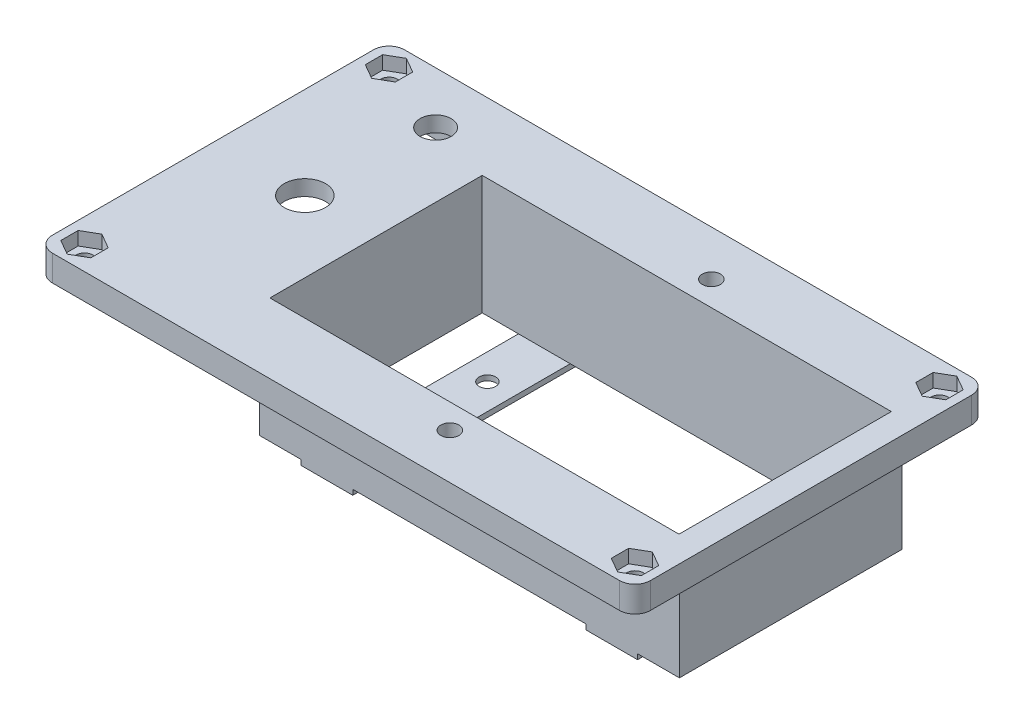
from build123d import *

# Parameters (mm, degrees)
SKETCH_1_R            = 1.6
EXTRUDE_1_DEPTH       = 2
EXTRUDE_1_2_DEPTH     = 4
CUT_EXTRUDE_5_DEPTH   = 2.01
SKETCH_4_R            = 1.6
EXTRUDE_2_DEPTH       = 3
CUT_EXTRUDE_1_DEPTH   = 2.6
SKETCH_6_W            = 79
SKETCH_6_H            = 41
CUT_EXTRUDE_2_DEPTH   = 8
SKETCH_7_W            = 81.076448847
SKETCH_7_H            = 43
SKETCH_7_W_2          = 79
SKETCH_7_H_2          = 41
EXTRUDE_3_DEPTH       = 20
SKETCH_9_R            = 3
CUT_EXTRUDE_3_DEPTH   = 4
SKETCH_10_R           = 4
CUT_EXTRUDE_4_DEPTH   = 4
SKETCH_11_W           = 10
SKETCH_11_H           = 43
SKETCH_11_R           = 1.6
EXTRUDE_4_DEPTH       = 1
SKETCH_12_W           = 10
SKETCH_12_H           = 7.5
EXTRUDE_5_DEPTH       = 3
SKETCH_13_R           = 1.75
CUT_EXTRUDE_5_2_DEPTH = 4


with BuildPart() as part:
    # Эскиз1 → Extrude 1 (new body)
    with BuildSketch(Plane(origin=(0, 0, 0), x_dir=(1, 0, 0), z_dir=(0, 1, 0))):
        with BuildLine():
            Line((55.077834671, -32.996915035), (-54.422165329, -32.996915035))
            ThreePointArc((-54.422165329, -32.996915035), (-56.543485673, -32.118235378), (-57.422165329, -29.996915035))
            Line((-57.422165329, -29.996915035), (-57.422165329, 32.003084965))
            ThreePointArc((-57.422165329, 32.003084965), (-56.543485673, 34.124405309), (-54.422165329, 35.003084965))
            Line((-54.422165329, 35.003084965), (55.077834671, 35.003084965))
            ThreePointArc((55.077834671, 35.003084965), (57.199155014, 34.124405309), (58.077834671, 32.003084965))
            Line((58.077834671, 32.003084965), (58.077834671, -29.996915035))
            ThreePointArc((58.077834671, -29.996915035), (57.199155014, -32.118235378), (55.077834671, -32.996915035))
        make_face()
        with Locations((53.477834671, -28.396915035)):
            Circle(SKETCH_1_R, mode=Mode.SUBTRACT)
        with Locations((-52.822165329, -28.396915035)):
            Circle(SKETCH_1_R, mode=Mode.SUBTRACT)
        with Locations((-52.822165329, 30.403084965)):
            Circle(SKETCH_1_R, mode=Mode.SUBTRACT)
        with Locations((53.477834671, 30.403084965)):
            Circle(SKETCH_1_R, mode=Mode.SUBTRACT)
        with BuildLine():
            Line((55.077834671, 28.003084965), (55.077834671, -25.996915035))
            Line((55.077834671, -25.996915035), (52.577834671, -25.996915035))
            ThreePointArc((52.577834671, -25.996915035), (51.517174499, -26.436254863), (51.077834671, -27.496915035))
            Line((51.077834671, -27.496915035), (51.077834671, -29.996915035))
            Line((51.077834671, -29.996915035), (-50.422165329, -29.996915035))
            Line((-50.422165329, -29.996915035), (-50.422165329, -27.496915035))
            ThreePointArc((-50.422165329, -27.496915035), (-50.861505157, -26.436254863), (-51.922165329, -25.996915035))
            Line((-51.922165329, -25.996915035), (-54.422165329, -25.996915035))
            Line((-54.422165329, -25.996915035), (-54.422165329, 28.003084965))
            Line((-54.422165329, 28.003084965), (-51.922165329, 28.003084965))
            ThreePointArc((-51.922165329, 28.003084965), (-50.861505157, 28.442424793), (-50.422165329, 29.503084965))
            Line((-50.422165329, 29.503084965), (-50.422165329, 32.003084965))
            Line((-50.422165329, 32.003084965), (51.077834671, 32.003084965))
            Line((51.077834671, 32.003084965), (51.077834671, 29.503084965))
            ThreePointArc((51.077834671, 29.503084965), (51.517174499, 28.442424793), (52.577834671, 28.003084965))
            Line((52.577834671, 28.003084965), (55.077834671, 28.003084965))
        make_face(mode=Mode.SUBTRACT)
    extrude(amount=EXTRUDE_1_DEPTH)

    # Эскиз2 → Extrude 1 2 (add)
    with BuildSketch(Plane(origin=(0, 2, 0), x_dir=(1, 0, 0), z_dir=(0, 1, 0))):
        with BuildLine():
            Line((-51.922165329, 28.003084965), (-54.422165329, 28.003084965))
            Line((-54.422165329, 28.003084965), (-54.422165329, -25.996915035))
            Line((-54.422165329, -25.996915035), (-51.922165329, -25.996915035))
            ThreePointArc((-51.922165329, -25.996915035), (-50.861505157, -26.436254863), (-50.422165329, -27.496915035))
            Line((-50.422165329, -27.496915035), (-50.422165329, -29.996915035))
            Line((-50.422165329, -29.996915035), (51.077834671, -29.996915035))
            Line((51.077834671, -29.996915035), (51.077834671, -27.496915035))
            ThreePointArc((51.077834671, -27.496915035), (51.517174499, -26.436254863), (52.577834671, -25.996915035))
            Line((52.577834671, -25.996915035), (55.077834671, -25.996915035))
            Line((55.077834671, -25.996915035), (55.077834671, 28.003084965))
            Line((55.077834671, 28.003084965), (52.577834671, 28.003084965))
            ThreePointArc((52.577834671, 28.003084965), (51.517174499, 28.442424793), (51.077834671, 29.503084965))
            Line((51.077834671, 29.503084965), (51.077834671, 32.003084965))
            Line((51.077834671, 32.003084965), (-50.422165329, 32.003084965))
            Line((-50.422165329, 32.003084965), (-50.422165329, 29.503084965))
            ThreePointArc((-50.422165329, 29.503084965), (-50.861505157, 28.442424793), (-51.922165329, 28.003084965))
        make_face()
        with BuildLine():
            Line((-51.922165329, 26.003084965), (-52.422165329, 26.003084965))
            Line((-52.422165329, 26.003084965), (-52.422165329, -23.996915035))
            Line((-52.422165329, -23.996915035), (-51.922165329, -23.996915035))
            ThreePointArc((-51.922165329, -23.996915035), (-49.447291595, -25.022041301), (-48.422165329, -27.496915035))
            Line((-48.422165329, -27.496915035), (-48.422165329, -27.996915035))
            Line((-48.422165329, -27.996915035), (49.077834671, -27.996915035))
            Line((49.077834671, -27.996915035), (49.077834671, -27.496915035))
            ThreePointArc((49.077834671, -27.496915035), (50.102960937, -25.022041301), (52.577834671, -23.996915035))
            Line((52.577834671, -23.996915035), (53.077834671, -23.996915035))
            Line((53.077834671, -23.996915035), (53.077834671, 26.003084965))
            Line((53.077834671, 26.003084965), (52.577834671, 26.003084965))
            ThreePointArc((52.577834671, 26.003084965), (50.102960937, 27.028211231), (49.077834671, 29.503084965))
            Line((49.077834671, 29.503084965), (49.077834671, 30.003084965))
            Line((49.077834671, 30.003084965), (-48.422165329, 30.003084965))
            Line((-48.422165329, 30.003084965), (-48.422165329, 29.503084965))
            ThreePointArc((-48.422165329, 29.503084965), (-49.447291595, 27.028211231), (-51.922165329, 26.003084965))
        make_face(mode=Mode.SUBTRACT)
    extrude(amount=-EXTRUDE_1_2_DEPTH)

    # Эскиз3 → Cut-Extrude 5 (cut)
    with BuildSketch(Plane.XZ.offset(2)):
        with BuildLine():
            Line((-50.622165329, 27.496915035), (-50.622165329, 30.196915035))
            Line((-50.622165329, 30.196915035), (51.277834671, 30.196915035))
            Line((51.277834671, 30.196915035), (51.277834671, 27.496915035))
            ThreePointArc((51.277834671, 27.496915035), (51.658595855, 26.577676219), (52.577834671, 26.196915035))
            Line((52.577834671, 26.196915035), (55.277834671, 26.196915035))
            Line((55.277834671, 26.196915035), (55.277834671, -28.203084965))
            Line((55.277834671, -28.203084965), (52.577834671, -28.203084965))
            ThreePointArc((52.577834671, -28.203084965), (51.658595855, -28.58384615), (51.277834671, -29.503084965))
            Line((51.277834671, -29.503084965), (51.277834671, -32.203084965))
            Line((51.277834671, -32.203084965), (-50.622165329, -32.203084965))
            Line((-50.622165329, -32.203084965), (-50.622165329, -29.503084965))
            ThreePointArc((-50.622165329, -29.503084965), (-51.002926514, -28.58384615), (-51.922165329, -28.203084965))
            Line((-51.922165329, -28.203084965), (-54.622165329, -28.203084965))
            Line((-54.622165329, -28.203084965), (-54.622165329, 26.196915035))
            Line((-54.622165329, 26.196915035), (-51.922165329, 26.196915035))
            ThreePointArc((-51.922165329, 26.196915035), (-51.002926514, 26.577676219), (-50.622165329, 27.496915035))
        make_face()
        with BuildLine():
            Line((-50.422165329, 27.496915035), (-50.422165329, 29.996915035))
            Line((-50.422165329, 29.996915035), (51.077834671, 29.996915035))
            Line((51.077834671, 29.996915035), (51.077834671, 27.496915035))
            ThreePointArc((51.077834671, 27.496915035), (51.517174499, 26.436254863), (52.577834671, 25.996915035))
            Line((52.577834671, 25.996915035), (55.077834671, 25.996915035))
            Line((55.077834671, 25.996915035), (55.077834671, -28.003084965))
            Line((55.077834671, -28.003084965), (52.577834671, -28.003084965))
            ThreePointArc((52.577834671, -28.003084965), (51.517174499, -28.442424793), (51.077834671, -29.503084965))
            Line((51.077834671, -29.503084965), (51.077834671, -32.003084965))
            Line((51.077834671, -32.003084965), (-50.422165329, -32.003084965))
            Line((-50.422165329, -32.003084965), (-50.422165329, -29.503084965))
            ThreePointArc((-50.422165329, -29.503084965), (-50.861505157, -28.442424793), (-51.922165329, -28.003084965))
            Line((-51.922165329, -28.003084965), (-54.422165329, -28.003084965))
            Line((-54.422165329, -28.003084965), (-54.422165329, 25.996915035))
            Line((-54.422165329, 25.996915035), (-51.922165329, 25.996915035))
            ThreePointArc((-51.922165329, 25.996915035), (-50.861505157, 26.436254863), (-50.422165329, 27.496915035))
        make_face(mode=Mode.SUBTRACT)
    extrude(amount=-CUT_EXTRUDE_5_DEPTH, mode=Mode.SUBTRACT)

    # Эскиз4 → Бобышка-Вытянуть2 (add)
    with BuildSketch(Plane(origin=(0, 2, 0), x_dir=(1, 0, 0), z_dir=(0, 1, 0))):
        with BuildLine():
            Line((-54.422165329, -32.996915035), (55.077834671, -32.996915035))
            ThreePointArc((55.077834671, -32.996915035), (57.199155014, -32.118235378), (58.077834671, -29.996915035))
            Line((58.077834671, -29.996915035), (58.077834671, 32.003084965))
            ThreePointArc((58.077834671, 32.003084965), (57.199155014, 34.124405309), (55.077834671, 35.003084965))
            Line((55.077834671, 35.003084965), (-54.422165329, 35.003084965))
            ThreePointArc((-54.422165329, 35.003084965), (-56.543485673, 34.124405309), (-57.422165329, 32.003084965))
            Line((-57.422165329, 32.003084965), (-57.422165329, -29.996915035))
            ThreePointArc((-57.422165329, -29.996915035), (-56.543485673, -32.118235378), (-54.422165329, -32.996915035))
        make_face()
        with Locations((-52.822165329, -28.396915035)):
            Circle(SKETCH_4_R, mode=Mode.SUBTRACT)
        with Locations((53.477834671, -28.396915035)):
            Circle(SKETCH_4_R, mode=Mode.SUBTRACT)
        with Locations((53.477834671, 30.403084965)):
            Circle(SKETCH_4_R, mode=Mode.SUBTRACT)
        with Locations((-52.822165329, 30.403084965)):
            Circle(SKETCH_4_R, mode=Mode.SUBTRACT)
    extrude(amount=EXTRUDE_2_DEPTH)

    # Эскиз5 → Вырез-Вытянуть1 (cut)
    with BuildSketch(Plane(origin=(0, 5, 0), x_dir=(1, 0, 0), z_dir=(0, 1, 0))):
        Polygon((-52.822165329, 27.054453404), (-49.922165329, 28.728769184), (-49.922165329, 32.077400746), (-52.822165329, 33.751716526), (-55.722165329, 32.077400746), (-55.722165329, 28.728769184), align=None)
        Polygon((56.377834671, 28.728769184), (53.477834671, 27.054453404), (50.577834671, 28.728769184), (50.577834671, 32.077400746), (53.477834671, 33.751716526), (56.377834671, 32.077400746), align=None)
        Polygon((53.477834671, -25.048283474), (50.577834671, -26.722599254), (50.577834671, -30.071230816), (53.477834671, -31.745546596), (56.377834671, -30.071230816), (56.377834671, -26.722599254), align=None)
        Polygon((-55.722165329, -26.722599254), (-52.822165329, -25.048283474), (-49.922165329, -26.722599254), (-49.922165329, -30.071230816), (-52.822165329, -31.745546596), (-55.722165329, -30.071230816), align=None)
    extrude(amount=-CUT_EXTRUDE_1_DEPTH, mode=Mode.SUBTRACT)

    # Эскиз6 → Вырез-Вытянуть2 (cut, through all)
    with BuildSketch(Plane(origin=(0, 5, 0), x_dir=(1, 0, 0), z_dir=(0, 1, 0))):
        with Locations((13.577834671, 1.003084965)):
            Rectangle(SKETCH_6_W, SKETCH_6_H)
    extrude(amount=-CUT_EXTRUDE_2_DEPTH, mode=Mode.SUBTRACT)

    # Эскиз7 → Бобышка-Вытянуть3 (add)
    with BuildSketch(Plane.XZ.offset(-2)):
        with Locations((13.616059095, -1.003084965)):
            Rectangle(SKETCH_7_W, SKETCH_7_H)
        with Locations((13.577834671, -1.003084965)):
            Rectangle(SKETCH_7_W_2, SKETCH_7_H_2, mode=Mode.SUBTRACT)
    extrude(amount=EXTRUDE_3_DEPTH)

    # Эскиз9 → Вырез-Вытянуть3 (cut, through all)
    with BuildSketch(Plane.XZ.offset(-2)):
        with Locations((-38.422165329, -25.003084965)):
            Circle(SKETCH_9_R)
    extrude(amount=-CUT_EXTRUDE_3_DEPTH, mode=Mode.SUBTRACT)

    # Эскиз10 → Вырез-Вытянуть4 (cut, through all)
    with BuildSketch(Plane.XZ.offset(-2)):
        with Locations((-39.672165329, -1.003084965)):
            Circle(SKETCH_10_R)
    extrude(amount=-CUT_EXTRUDE_4_DEPTH, mode=Mode.SUBTRACT)

    # Эскиз11 → Бобышка-Вытянуть4 (add)
    with BuildSketch(Plane.XZ.offset(18)):
        with Locations((-13.922165329, -1.003084965)):
            Rectangle(SKETCH_11_W, SKETCH_11_H)
        with Locations((-13.922165329, 8.496915035)):
            Circle(SKETCH_11_R, mode=Mode.SUBTRACT)
        with Locations((-13.922165329, -10.503084965)):
            Circle(SKETCH_11_R, mode=Mode.SUBTRACT)
        with Locations((41.077834671, -1.003084965)):
            Rectangle(SKETCH_11_W, SKETCH_11_H)
        with Locations((41.077834671, -10.503084965)):
            Circle(SKETCH_11_R, mode=Mode.SUBTRACT)
        with Locations((41.077834671, 8.496915035)):
            Circle(SKETCH_11_R, mode=Mode.SUBTRACT)
    extrude(amount=EXTRUDE_4_DEPTH)

    # Эскиз12 → Бобышка-Вытянуть5 (add)
    with BuildSketch(Plane.XZ.offset(-2)):
        with Locations((13.577834671, -26.253084965)):
            Rectangle(SKETCH_12_W, SKETCH_12_H)
        Polygon((13.577834671, -29.601716526), (16.477834671, -27.927400746), (16.477834671, -24.578769184), (13.577834671, -22.904453404), (10.677834671, -24.578769184), (10.677834671, -27.927400746), align=None, mode=Mode.SUBTRACT)
        with Locations((13.577834671, 24.246915035)):
            Rectangle(SKETCH_12_W, SKETCH_12_H)
        Polygon((13.577834671, 21.016139597), (16.375768274, 22.631527316), (16.375768274, 25.862302754), (13.577834671, 27.477690473), (10.779901068, 25.862302754), (10.779901068, 22.631527316), align=None, mode=Mode.SUBTRACT)
    extrude(amount=EXTRUDE_5_DEPTH)

    # Эскиз13 → Cut-Extrude 5 2 (cut, through all)
    with BuildSketch(Plane.XZ.offset(-2)):
        with Locations((13.577834671, 24.246915035)):
            Circle(SKETCH_13_R)
        with Locations((13.577834671, -26.253084965)):
            Circle(SKETCH_13_R)
    extrude(amount=-CUT_EXTRUDE_5_2_DEPTH, mode=Mode.SUBTRACT)


solid = part.part
